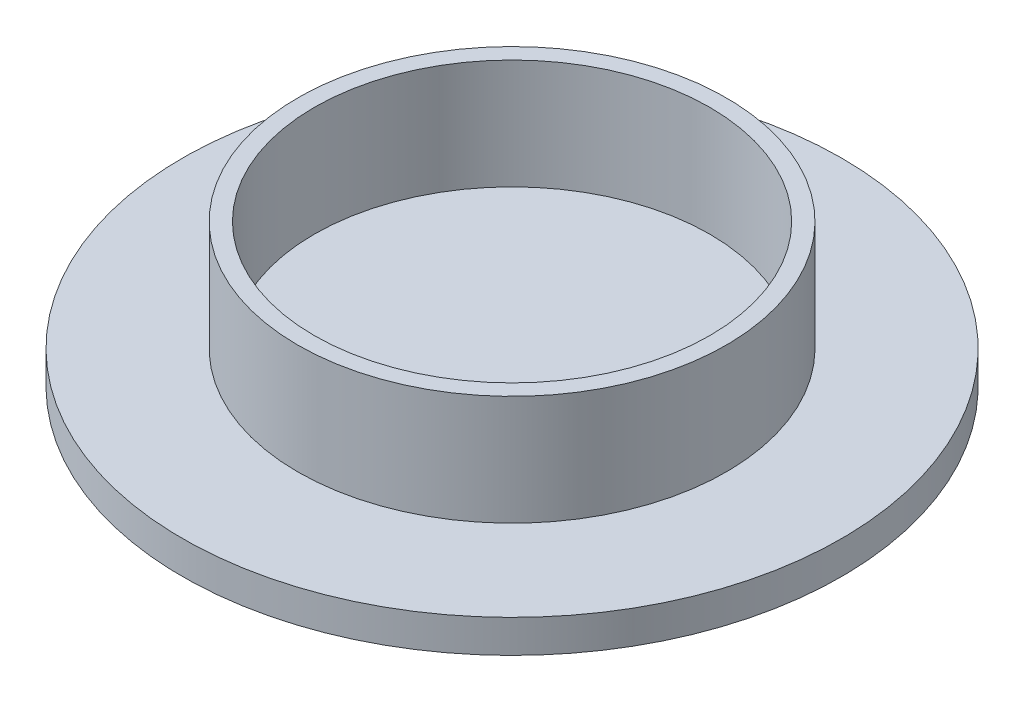
from build123d import *

# Parameters (mm, degrees)
SKETCH_1_R      = 19.5
SKETCH_1_R_2    = 18
EXTRUDE_1_DEPTH = 10
SKETCH_3_R      = 30
EXTRUDE_2_DEPTH = 3


with BuildPart() as part:
    # 草圖1 → 填料-伸長1 (new body)
    with BuildSketch(Plane(origin=(0, 0, 0), x_dir=(1, 0, 0), z_dir=(0, 1, 0))):
        Circle(SKETCH_1_R)
        Circle(SKETCH_1_R_2, mode=Mode.SUBTRACT)
    extrude(amount=EXTRUDE_1_DEPTH)

    # 草圖3 → 填料-伸長2 (add)
    with BuildSketch(Plane.XZ):
        Circle(SKETCH_3_R)
    extrude(amount=EXTRUDE_2_DEPTH)


solid = part.part
